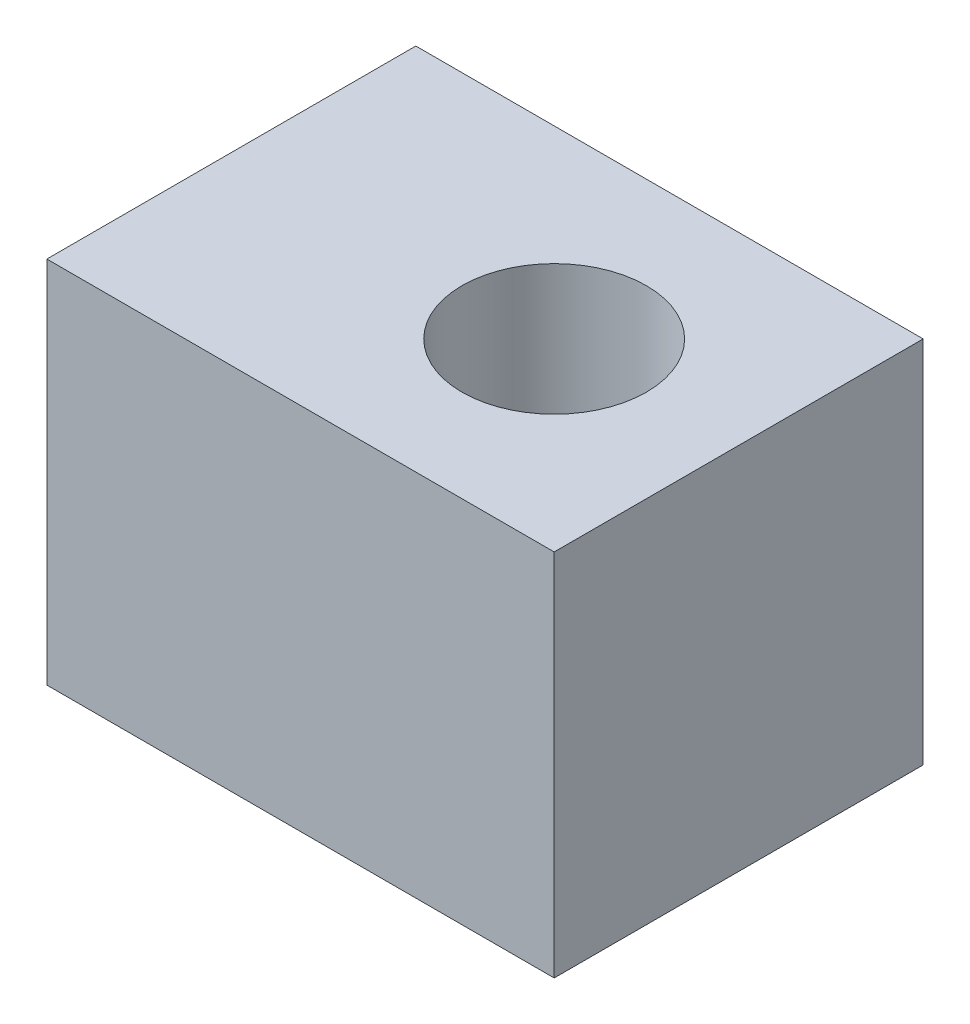
from build123d import *

# Parameters (mm, degrees)
SKETCH1_W           = 22
SKETCH1_H           = 16
BOSS_EXTRUDE1_DEPTH = 16
SKETCH2_R           = 4
CUT_EXTRUDE1_DEPTH  = 8
SKETCH3_R           = 4
CUT_EXTRUDE2_DEPTH  = 17


with BuildPart() as part:
    # Sketch1 → Boss-Extrude1 (new body)
    with BuildSketch(Plane.XY):
        with Locations((11, 8)):
            Rectangle(SKETCH1_W, SKETCH1_H)
    extrude(amount=BOSS_EXTRUDE1_DEPTH)

    # Sketch2 → Cut-Extrude1 (cut)
    with BuildSketch(Plane.ZY):
        with Locations(Location((8, 8, 0), (0, 0, 270))):  # turned: the seam where the file's is
            Circle(SKETCH2_R)
    extrude(amount=-CUT_EXTRUDE1_DEPTH, mode=Mode.SUBTRACT)

    # Sketch3 → Cut-Extrude2 (cut, through all)
    with BuildSketch(Plane.XZ):
        with Locations(Location((14, 8, 0), (0, 0, 270))):  # turned: the seam where the file's is
            Circle(SKETCH3_R)
    extrude(amount=-CUT_EXTRUDE2_DEPTH, mode=Mode.SUBTRACT)


solid = part.part
